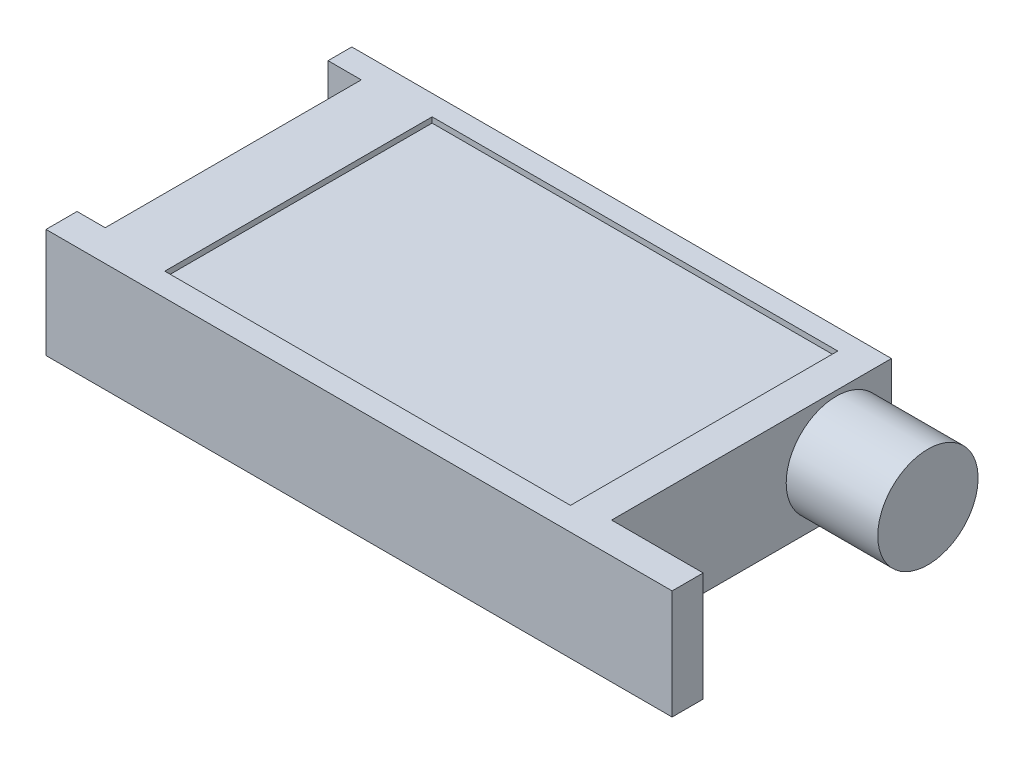
from build123d import *

# Parameters (mm, degrees)
BOSS_EXTRUDE1_DEPTH = 20
SKETCH2_R           = 9.180948857
BOSS_EXTRUDE2_DEPTH = 16.762555
SKETCH3_W           = 74.249943047
SKETCH3_H           = 48.931949377
CUT_EXTRUDE1_DEPTH  = 1


with BuildPart() as part:
    # Sketch1 → Boss-Extrude1 (new body)
    with BuildSketch(Plane(origin=(0, 0, 0), x_dir=(1, 0, 0), z_dir=(0, 1, 0))):
        Polygon((-50.055146164, 21.646889896), (-50.055146164, -25.226179967), (-55.206550944, -25.226179967), (-55.206550944, -30.910542614), (-31.621863062, -30.910542614), (17.979762571, -30.910542614), (59.391812496, -30.910542614), (59.391812496, -25.226179967), (42.62925771, -25.226179967), (42.62925771, 25.999180786), (-46.65640648, 25.999180786), (-56.142161298, 25.999180786), (-56.142161298, 21.646889896), align=None)
    extrude(amount=BOSS_EXTRUDE1_DEPTH)

    # Sketch2 → Boss-Extrude2 (add)
    with BuildSketch(Plane(origin=(42.62925771, 0, 0), x_dir=(0, 0, -1), z_dir=(1, 0, 0))):
        with Locations(Location((15.911282323, 9.888690044, 0), (0, 0, 180))):  # turned: the seam where the file's is
            Circle(SKETCH2_R)
    extrude(amount=BOSS_EXTRUDE2_DEPTH)

    # Sketch3 → Cut-Extrude1 (cut)
    with BuildSketch(Plane(origin=(0, 20, 0), x_dir=(1, 0, 0), z_dir=(0, 1, 0))):
        with Locations((-0.592763324, -2.194150519)):
            Rectangle(SKETCH3_W, SKETCH3_H)
    extrude(amount=-CUT_EXTRUDE1_DEPTH, mode=Mode.SUBTRACT)


solid = part.part
